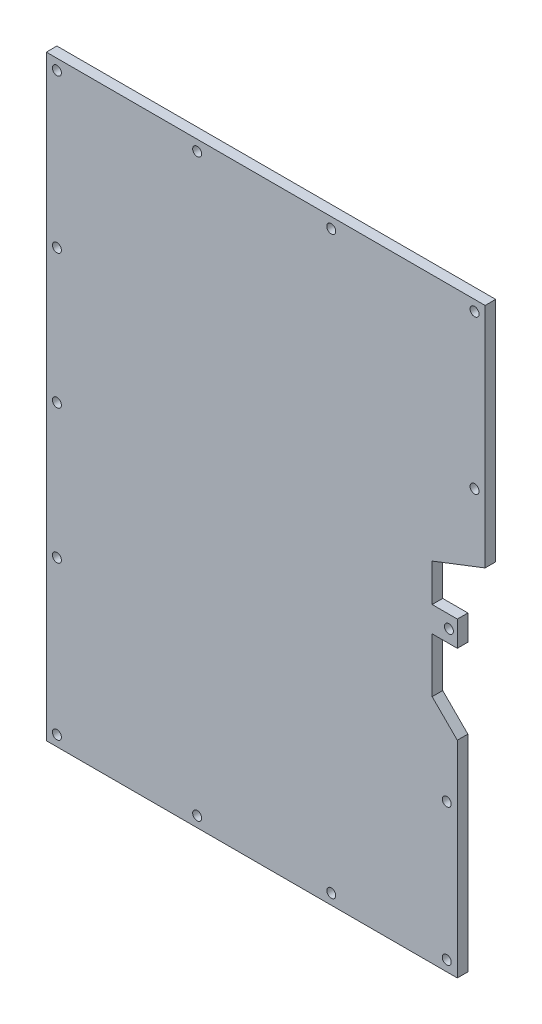
from build123d import *

# Parameters (mm, degrees)
SKETCH1_R      = 0.85
EXTRUDE1_DEPTH = 2


with BuildPart() as part:
    # Sketch1 → Extrude1 (new body)
    with BuildSketch(Plane.XY):
        Polygon((-79.375, -56.4375), (-79.375, 56.4375), (3.675, 56.4375), (3.675, 13.405219977), (-6.35, 9.525), (-6.35, 2.4), (-1.5875, 2.4), (-1.5875, -2.4), (-6.35, -2.4), (-6.35, -12.7), (-1.5875, -17.4625), (-1.5875, -56.4375), align=None)
        with Locations((-3.175, 0)):
            Circle(SKETCH1_R, mode=Mode.SUBTRACT)
        with Locations((1.675, 54.4375)):
            Circle(SKETCH1_R, mode=Mode.SUBTRACT)
        with Locations((-25.443833121, 54.4375)):
            Circle(SKETCH1_R, mode=Mode.SUBTRACT)
        with Locations((-50.829063022, 54.4375)):
            Circle(SKETCH1_R, mode=Mode.SUBTRACT)
        with Locations((-77.375, 54.4375)):
            Circle(SKETCH1_R, mode=Mode.SUBTRACT)
        with Locations((-77.375, 25.386437646)):
            Circle(SKETCH1_R, mode=Mode.SUBTRACT)
        with Locations((-77.375, 0)):
            Circle(SKETCH1_R, mode=Mode.SUBTRACT)
        with Locations((-77.375, -25.408441217)):
            Circle(SKETCH1_R, mode=Mode.SUBTRACT)
        with Locations((-77.375, -54.4375)):
            Circle(SKETCH1_R, mode=Mode.SUBTRACT)
        with Locations((-50.829063022, -54.4375)):
            Circle(SKETCH1_R, mode=Mode.SUBTRACT)
        with Locations((-25.443833121, -54.4375)):
            Circle(SKETCH1_R, mode=Mode.SUBTRACT)
        with Locations((-3.5875, -54.4375)):
            Circle(SKETCH1_R, mode=Mode.SUBTRACT)
        with Locations((-3.5875, -28.51830741)):
            Circle(SKETCH1_R, mode=Mode.SUBTRACT)
        with Locations((1.675, 25.386437646)):
            Circle(SKETCH1_R, mode=Mode.SUBTRACT)
    extrude(amount=EXTRUDE1_DEPTH)


solid = part.part
